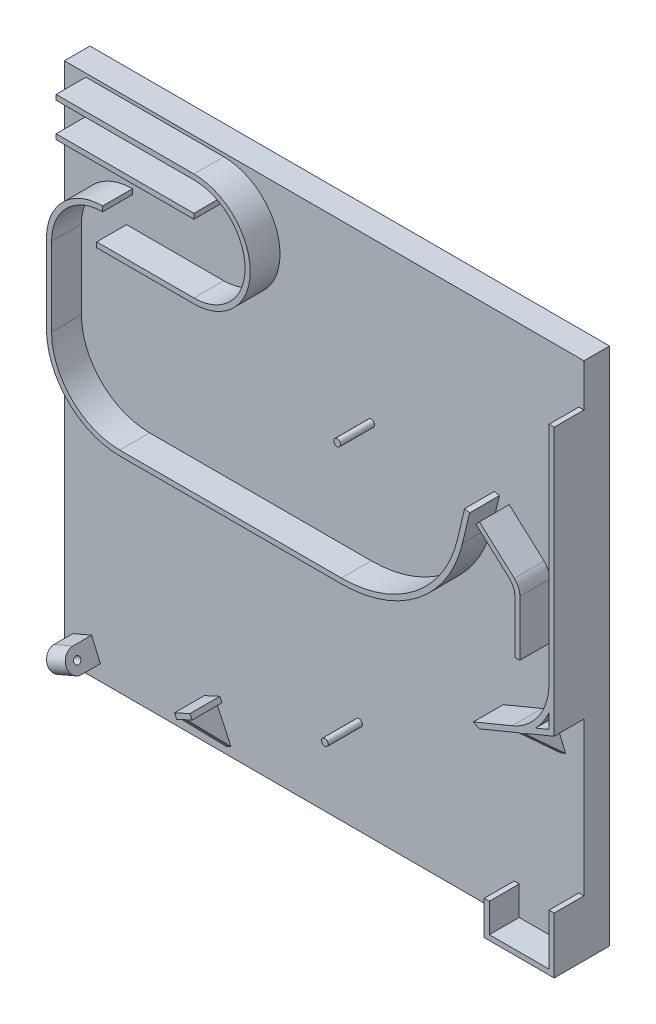
from build123d import *

# Parameters (mm, degrees)
SKETCH2_W           = 304.8
SKETCH2_H           = 304.8
BOSS_EXTRUDE1_DEPTH = 15
BOSS_EXTRUDE2_DEPTH = 17.5
CUT_EXTRUDE1_DEPTH  = 17.5
CUT_EXTRUDE2_DEPTH  = 17.5
CUT_EXTRUDE3_DEPTH  = 17.5
CUT_EXTRUDE4_DEPTH  = 17.5
CUT_EXTRUDE5_DEPTH  = 17.5
SKETCH2_5_R         = 2
BOSS_EXTRUDE3_DEPTH = 20
SKETCH8_W           = 20
SKETCH8_H           = 95
BOSS_EXTRUDE4_DEPTH = 45
CUT_EXTRUDE6_DEPTH  = 45
SKETCH11_W          = 12.681432754
SKETCH11_H          = 17.5
CUT_EXTRUDE8_DEPTH  = 35
SKETCH10_R          = 2
CUT_EXTRUDE7_DEPTH  = 45


with BuildPart() as part:
    # Sketch2 → Boss-Extrude1 (new body)
    with BuildSketch(Plane.XY):
        with Locations((152.4, 152.4)):
            Rectangle(SKETCH2_W, SKETCH2_H)
    extrude(amount=-BOSS_EXTRUDE1_DEPTH)

    # Sketch2_3 → Boss-Extrude2 (add)
    # profile 1 of 8: a face of its own
    with BuildSketch(Plane.XY):
        Polygon((93.5, 282.8), (0, 282.8), (0, 279.8), (21.107831574, 279.8), (21.107831574, 263.8), (24.107831574, 263.8), (24.107831574, 279.8), (93.5, 279.8), align=None)
    # profile 2 of 8: a face of its own
    with BuildSketch(Plane.XY):
        with BuildLine():
            Line((0, 302.8), (0, 299.8))
            Line((0, 299.8), (93.5, 299.8))
            ThreePointArc((93.5, 299.8), (123.5, 269.8), (93.5, 239.8))
            Line((93.5, 239.8), (36.5, 239.8))
            Line((36.5, 239.8), (36.5, 236.8))
            Line((36.5, 236.8), (46.34178582, 236.8))
            Line((46.34178582, 236.8), (46.34178582, 219.3))
            Line((46.34178582, 219.3), (49.34178582, 219.3))
            Line((49.34178582, 219.3), (49.34178582, 236.8))
            Line((49.34178582, 236.8), (93.5, 236.8))
            ThreePointArc((93.5, 236.8), (126.5, 269.8), (93.5, 302.8))
            Line((93.5, 302.8), (0, 302.8))
        make_face()
    # profile 3 of 8: a face of its own
    with BuildSketch(Plane.XY):
        Polygon((263.8, 20), (263.8, 0), (304.8, 0), (304.8, 33), (301.8, 33), (301.8, 3), (266.8, 3), (266.8, 20), align=None)
    # profile 4 of 8: a face of its own
    with BuildSketch(Plane.XY):
        with BuildLine():
            Line((304.8, 279.8), (301.8, 279.8))
            Line((301.8, 279.8), (301.8, 148.186252327))
            ThreePointArc((301.8, 148.186252327), (295.901436431, 128.741294171), (280.193920133, 115.850468689))
            Line((280.193920133, 115.850468689), (257.453782439, 106.431195246))
            Line((257.453782439, 106.431195246), (260.952988472, 104.633437242))
            Line((260.952988472, 104.633437242), (284.733622888, 114.483698539))
            Line((284.733622888, 114.483698539), (291.239241238, 98.777746486))
            Line((291.239241238, 98.777746486), (294.010879835, 99.925796783))
            Line((294.010879835, 99.925796783), (287.505261485, 115.631748836))
            Line((287.505261485, 115.631748836), (304.8, 122.795464086))
            Line((304.8, 122.795464086), (304.8, 279.8))
        make_face()
        with BuildLine():
            Line((301.8, 133.38760374), (301.8, 124.8))
            Line((301.8, 124.8), (293.866088671, 121.513666325))
            ThreePointArc((293.866088671, 121.513666325), (298.395845267, 127.074583472), (301.8, 133.38760374))
        make_face(mode=Mode.SUBTRACT)
    # profile 5 of 8: a face of its own
    with BuildSketch(Plane.XY):
        with BuildLine():
            ThreePointArc((10, 226.8), (18.786796564, 248.013203436), (40, 256.8))
            Line((40, 256.8), (40, 259.8))
            ThreePointArc((40, 259.8), (16.665476221, 250.134523779), (7, 226.8))
            Line((7, 226.8), (7, 180.8))
            ThreePointArc((7, 180.8), (19.597686711, 150.386493887), (50.011192824, 137.788807176))
            Line((50.011192824, 137.788807176), (112.853619172, 137.788807176))
            Line((112.853619172, 137.788807176), (112.853619172, 121.788807176))
            Line((112.853619172, 121.788807176), (115.853619172, 121.788807176))
            Line((115.853619172, 121.788807176), (115.853619172, 137.788807176))
            Line((115.853619172, 137.788807176), (180.011192824, 137.788807176))
            ThreePointArc((180.011192824, 137.788807176), (225.294551046, 153.531340693), (251.047093253, 193.969150516))
            Line((251.047093253, 193.969150516), (255.194405854, 211.484851991))
            Line((255.194405854, 211.484851991), (252.275122275, 212.176070758))
            Line((252.275122275, 212.176070758), (248.127809674, 194.660369283))
            ThreePointArc((248.127809674, 194.660369283), (223.433591119, 155.884387261), (180.011192824, 140.788807176))
            Line((180.011192824, 140.788807176), (50.011192824, 140.788807176))
            ThreePointArc((50.011192824, 140.788807176), (21.719007055, 152.507814231), (10, 180.8))
            Line((10, 180.8), (10, 226.8))
        make_face()
    # profile 6 of 8: a face of its own
    with BuildSketch(Plane.XY):
        with BuildLine():
            Line((281.733622888, 151.387820597), (284.733622888, 151.387820597))
            Line((284.733622888, 151.387820597), (284.733622888, 183.935533743))
            ThreePointArc((284.733622888, 183.935533743), (283.869077464, 188.002900174), (281.424928951, 191.366981998))
            Line((281.424928951, 191.366981998), (260.952988472, 209.8))
            Line((260.952988472, 209.8), (258.945596653, 207.570565524))
            Line((258.945596653, 207.570565524), (278.424928951, 190.031295942))
            ThreePointArc((278.424928951, 190.031295942), (280.869077464, 186.667214118), (281.733622888, 182.599847688))
            Line((281.733622888, 182.599847688), (281.733622888, 151.387820597))
        make_face()
    # profile 7 of 8: a face of its own
    with BuildSketch(Plane.XY):
        Polygon((86.547634765, 22.126155741), (95, 4), (97.718923361, 5.267854785), (89.266558126, 23.394010526), (92.438635381, 24.873174442), (91.199667441, 27.530149764), (82.126335472, 23.374526297), (83.375557511, 20.646991825), align=None)
    # profile 8 of 8: a face of its own
    with BuildSketch(Plane.XY):
        Polygon((16, 21), (5, 16.3), (10.107831574, 4.345500571), (21.107831574, 9.045500571), align=None)
    extrude(amount=BOSS_EXTRUDE2_DEPTH)

    # Sketch3 → Cut-Extrude1 (cut)
    with BuildSketch(Plane(origin=(79.564500346, 37.101535829, 0), x_dir=(0, 0, 1), z_dir=(-0.9063077870366483, -0.422618261740703, 0))):
        Polygon((17.5, -16.523503717), (0, -36.523503717), (17.5, -36.523503717), align=None)
    extrude(amount=-CUT_EXTRUDE1_DEPTH, mode=Mode.SUBTRACT)

    # Sketch4 → Cut-Extrude2 (cut)
    with BuildSketch(Plane(origin=(283.511449018, 117.434287271, 0), x_dir=(0, 0, 1), z_dir=(-0.923879532511288, -0.3826834323650868, 0))):
        Polygon((17.5, -3.452640544), (0, -20.19369423), (17.5, -20.19369423), align=None)
    extrude(amount=-CUT_EXTRUDE2_DEPTH, mode=Mode.SUBTRACT)

    # Sketch5 → Cut-Extrude3 (cut)
    with BuildSketch(Plane.ZY.offset(-112.853619172)):
        Polygon((17.5, 137.788807176), (17.5, 121.788807176), (0, 121.788807176), align=None)
    extrude(amount=-CUT_EXTRUDE3_DEPTH, mode=Mode.SUBTRACT)

    # Sketch6 → Cut-Extrude4 (cut)
    with BuildSketch(Plane.ZY.offset(-46.34178582)):
        Polygon((17.5, 236.8), (17.5, 219.3), (0, 219.3), align=None)
    extrude(amount=-CUT_EXTRUDE4_DEPTH, mode=Mode.SUBTRACT)

    # Sketch7 → Cut-Extrude5 (cut)
    with BuildSketch(Plane.ZY.offset(-21.107831574)):
        Polygon((17.5, 279.8), (0, 263.8), (17.5, 263.8), align=None)
    extrude(amount=-CUT_EXTRUDE5_DEPTH, mode=Mode.SUBTRACT)

    # Sketch2_5 → Boss-Extrude3 (add)
    with BuildSketch(Plane.XY):
        with Locations((180.011192824, 210.788807176)):
            Circle(SKETCH2_5_R)
        with Locations((172.8, 55)):
            Circle(SKETCH2_5_R)
    extrude(amount=BOSS_EXTRUDE3_DEPTH)

    # Sketch8 → Boss-Extrude4 (add)
    with BuildSketch(Plane(origin=(0, 0, -15), x_dir=(-1, 0, 0), z_dir=(0, 0, -1))):
        with Locations((-152.4, 47.5)):
            Rectangle(SKETCH8_W, SKETCH8_H)
    extrude(amount=BOSS_EXTRUDE4_DEPTH)

    # Sketch9 → Cut-Extrude6 (cut)
    with BuildSketch(Plane(origin=(162.4, 0, 0), x_dir=(0, 0, -1), z_dir=(1, 0, 0))):
        Polygon((45.99140235, 95), (60, 95), (60, 0), align=None)
    extrude(amount=-CUT_EXTRUDE6_DEPTH, mode=Mode.SUBTRACT)

    # Sketch11 → Cut-Extrude8 (cut)
    with BuildSketch(Plane.XZ.offset(-279.8)):
        with Locations((6.340716377, 8.75)):
            Rectangle(SKETCH11_W, SKETCH11_H)
    extrude(amount=-CUT_EXTRUDE8_DEPTH, mode=Mode.SUBTRACT)

    # Sketch10 → Cut-Extrude7 (cut)
    with BuildSketch(Plane(origin=(10.11747851, 4.322922636, 0), x_dir=(0, 0, 1), z_dir=(-0.9195768791852732, -0.39291012110643525, 0))):
        with BuildLine():
            Line((17.5, 13.024552525), (11, 13.024552525))
            ThreePointArc((11, 13.024552525), (15.596194078, 11.120746603), (17.5, 6.524552525))
            Line((17.5, 6.524552525), (17.5, 13.024552525))
        make_face()
        with BuildLine():
            Line((17.5, 0.024552525), (17.5, 6.524552525))
            ThreePointArc((17.5, 6.524552525), (15.596194078, 1.928358447), (11, 0.024552525))
            Line((11, 0.024552525), (17.5, 0.024552525))
        make_face()
        with Locations((11, 6.524552525)):
            Circle(SKETCH10_R)
    extrude(amount=-CUT_EXTRUDE7_DEPTH, mode=Mode.SUBTRACT)


solid = part.part
